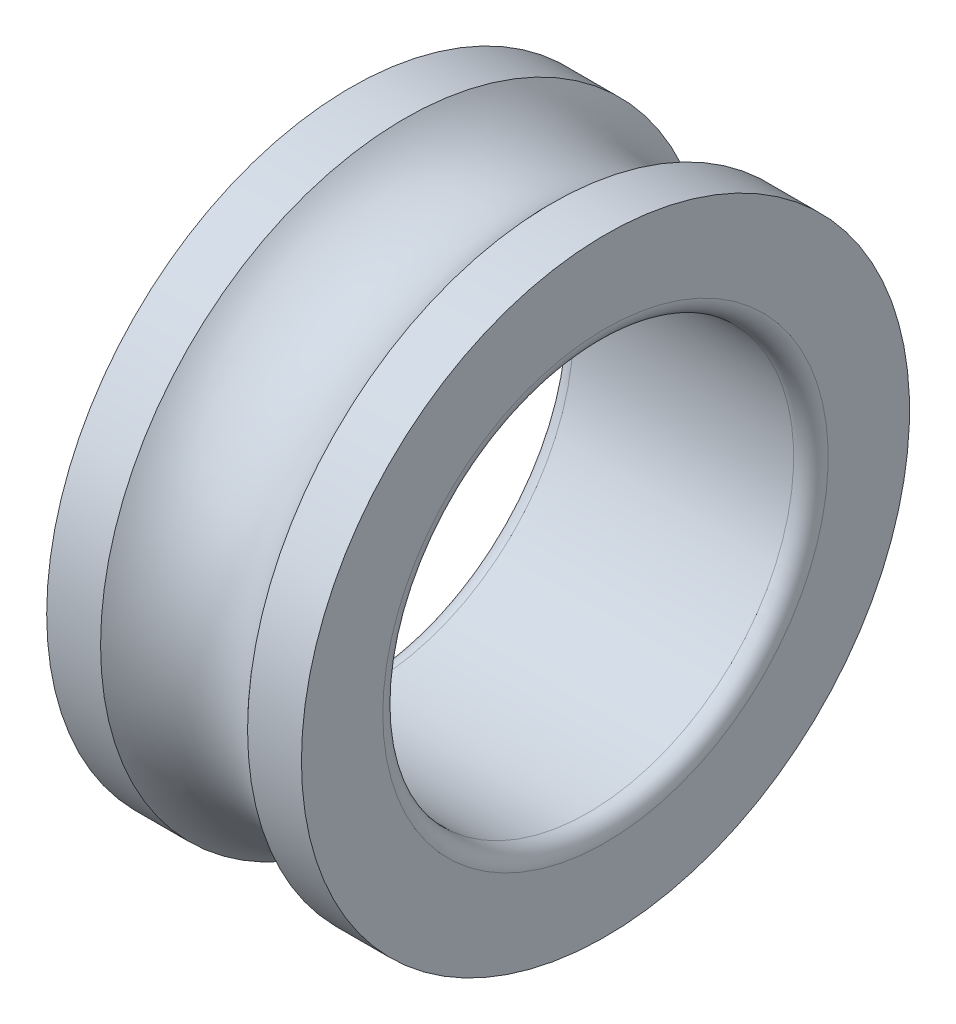
from build123d import *


with BuildPart() as part:
    # Sketch1 → Revolve1 (revolve)
    with BuildSketch(Plane.XY):
        with BuildLine():
            Line((13.4, 25), (-13.4, 25))
            ThreePointArc((-13.4, 25), (-14.88492424, 25.61507576), (-15.5, 27.1))
            Line((-15.5, 27.1), (-15.5, 37))
            Line((-15.5, 37), (-8.94427191, 37))
            ThreePointArc((-8.94427191, 37), (0, 33), (8.94427191, 37))
            Line((8.94427191, 37), (15.5, 37))
            Line((15.5, 37), (15.5, 27.1))
            ThreePointArc((15.5, 27.1), (14.88492424, 25.61507576), (13.4, 25))
        make_face()
    revolve(axis=Axis((-15.5, 0, 0), (1, 0, 0)))


solid = part.part
